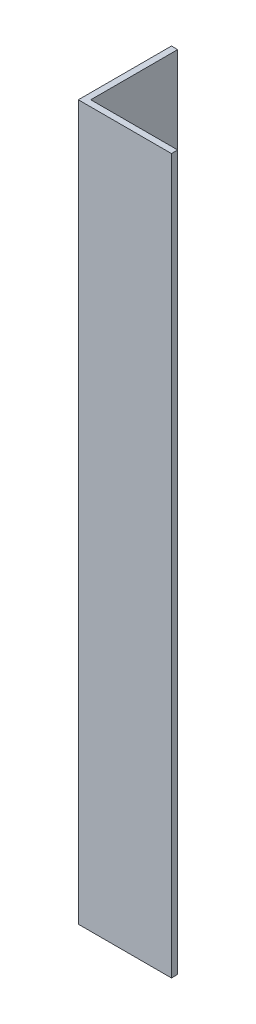
from build123d import *

# Parameters (mm, degrees)
EXTRUDE_1_DEPTH = 115


with BuildPart() as part:
    # Эскиз1 → Бобышка-Вытянуть1 (new body)
    with BuildSketch(Plane(origin=(0, 0, 0), x_dir=(1, 0, 0), z_dir=(0, 1, 0))):
        Polygon((0, 0), (0, 15), (1, 15), (1, 1), (15, 1), (15, 0), align=None)
    extrude(amount=EXTRUDE_1_DEPTH)


solid = part.part
